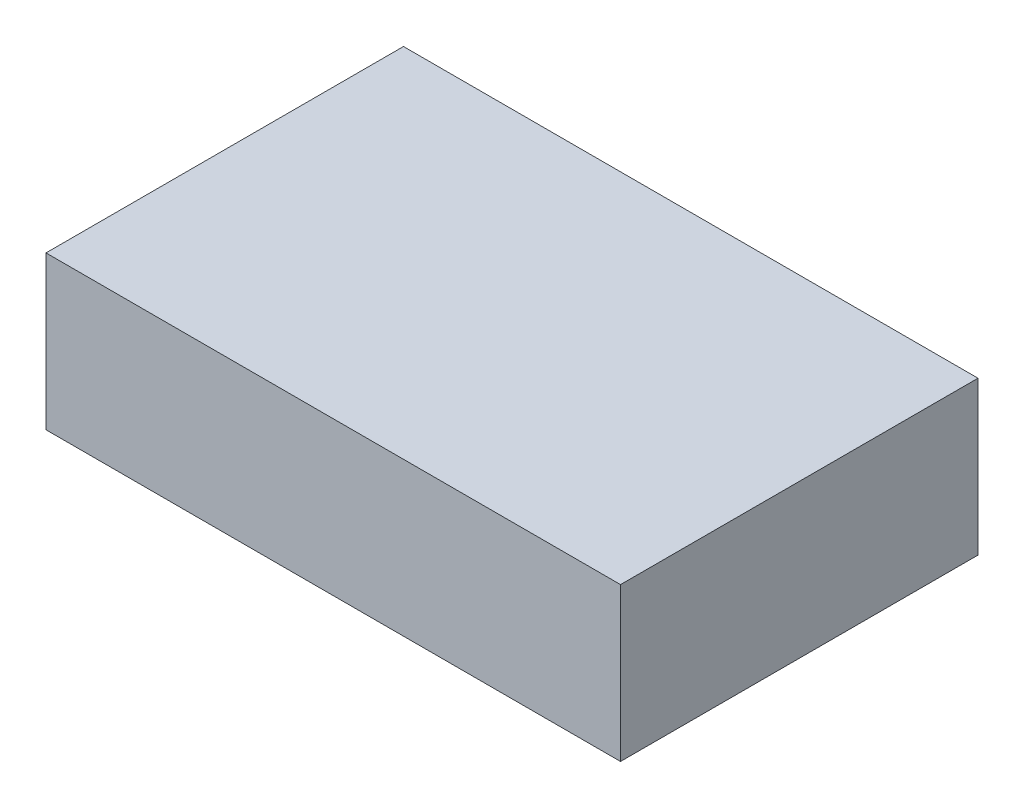
from build123d import *

# Parameters (mm, degrees)
SKETCH_1_W            = 90
SKETCH_1_H            = 56
EXTRUDE_1_DEPTH       = 24
SKETCH_2_R            = 1.5
CUT_EXTRUDE_697_DEPTH = 10


with BuildPart() as part:
    # 草图1 → 凸台-拉伸1 (new body)
    with BuildSketch(Plane(origin=(0, 0, 0), x_dir=(1, 0, 0), z_dir=(0, 1, 0))):
        Rectangle(SKETCH_1_W, SKETCH_1_H)
    extrude(amount=EXTRUDE_1_DEPTH)

    # 草图2 → Cut-Extrude 697 (cut)
    with BuildSketch(Plane.XZ):
        with Locations((-42, 25)):
            Circle(SKETCH_2_R)
        with Locations((16, 25)):
            Circle(SKETCH_2_R)
        with Locations((16, -25)):
            Circle(SKETCH_2_R)
        with Locations((-42, -25)):
            Circle(SKETCH_2_R)
    extrude(amount=-CUT_EXTRUDE_697_DEPTH, mode=Mode.SUBTRACT)


solid = part.part
